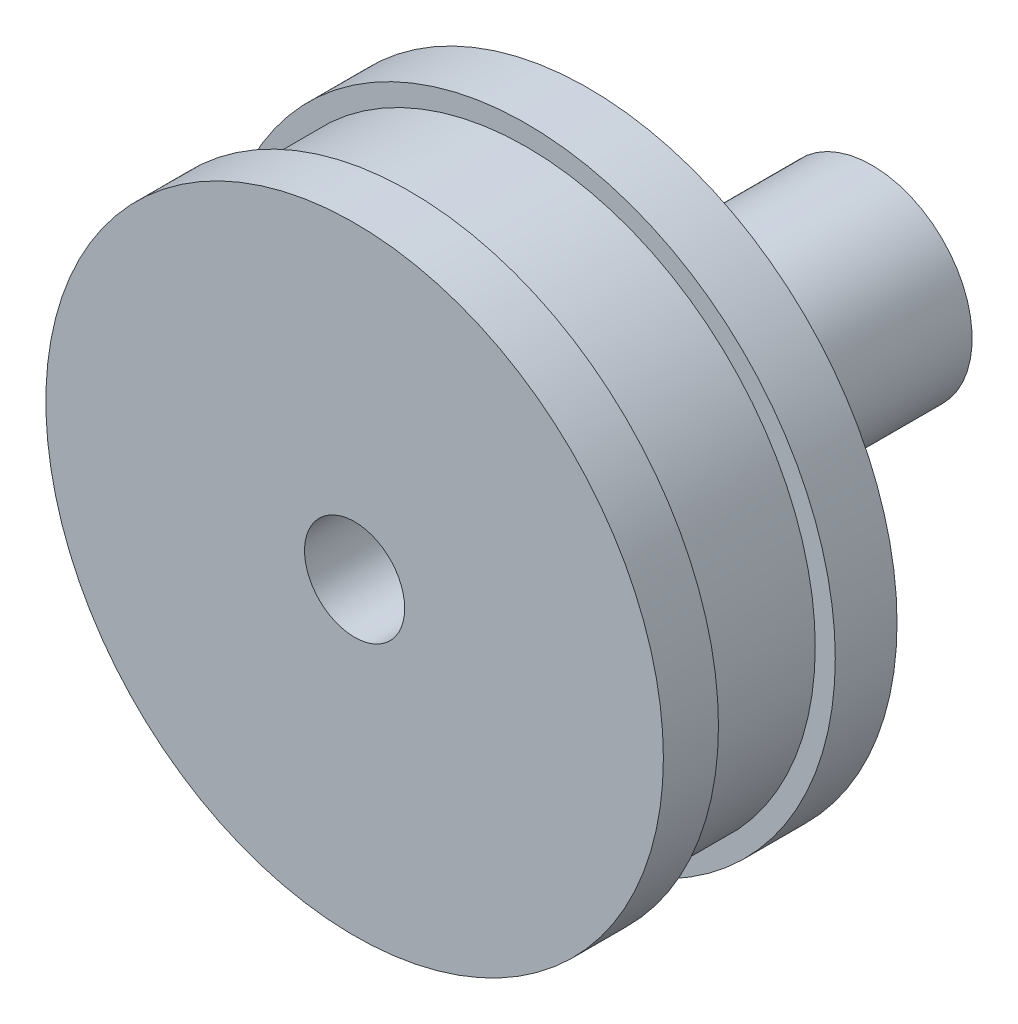
from build123d import *

# Parameters (mm, degrees)
SKETCH_1_R          = 18.5
SKETCH_1_R_2        = 3
EXTRUDE_1_DEPTH     = 14
CUT_EXTRUDE_START   = -2.2
SKETCH_2_R          = 18.5
SKETCH_2_R_2        = 17.3
CUT_EXTRUDE_1_DEPTH = 2.2
SKETCH_2_2_R        = 18.5
SKETCH_2_2_R_2      = 17.3
CUT_EXTRUDE_2_DEPTH = 0.8
CUT_EXTRUDE_START_2 = -4
SKETCH_2_4_R        = 18.5
SKETCH_2_4_R_2      = 17.3
CUT_EXTRUDE_3_DEPTH = 4
SKETCH_2_6_R        = 18.5
SKETCH_2_6_R_2      = 17.3
CUT_EXTRUDE_5_DEPTH = 3
SKETCH_3_R          = 7
EXTRUDE_3_DEPTH     = 5
SKETCH_4_R          = 6
EXTRUDE_4_DEPTH     = 12


with BuildPart() as part:
    # 草图1 → 凸台-拉伸1 (new body)
    with BuildSketch(Plane.XY):
        Circle(SKETCH_1_R)
        Circle(SKETCH_1_R_2, mode=Mode.SUBTRACT)
    extrude(amount=EXTRUDE_1_DEPTH)

    # 草图2 → 切除-拉伸1 (cut)
    with BuildSketch(Plane.XY.offset(7.7).offset(CUT_EXTRUDE_START)):
        Circle(SKETCH_2_R)
        Circle(SKETCH_2_R_2, mode=Mode.SUBTRACT)
    extrude(amount=CUT_EXTRUDE_1_DEPTH, mode=Mode.SUBTRACT)

    # 草图2<2> → 切除-拉伸2 (cut)
    with BuildSketch(Plane.XY.offset(7.7)):
        Circle(SKETCH_2_2_R)
        Circle(SKETCH_2_2_R_2, mode=Mode.SUBTRACT)
    extrude(amount=CUT_EXTRUDE_2_DEPTH, mode=Mode.SUBTRACT)

    # 草图2<4> → 切除-拉伸3 (cut)
    with BuildSketch(Plane.XY.offset(7.7).offset(CUT_EXTRUDE_START_2)):
        Circle(SKETCH_2_4_R)
        Circle(SKETCH_2_4_R_2, mode=Mode.SUBTRACT)
    extrude(amount=CUT_EXTRUDE_3_DEPTH, mode=Mode.SUBTRACT)

    # 草图2<6> → 切除-拉伸5 (cut)
    with BuildSketch(Plane.XY.offset(7.7)):
        Circle(SKETCH_2_6_R)
        Circle(SKETCH_2_6_R_2, mode=Mode.SUBTRACT)
    extrude(amount=CUT_EXTRUDE_5_DEPTH, mode=Mode.SUBTRACT)

    # 草图3 → 凸台-拉伸3 (add)
    with BuildSketch(Plane(origin=(0, 0, 0), x_dir=(-1, 0, 0), z_dir=(0, 0, -1))):
        Circle(SKETCH_3_R)
    extrude(amount=EXTRUDE_3_DEPTH)

    # 草图4 → 凸台-拉伸4 (add)
    with BuildSketch(Plane(origin=(0, 0, -5), x_dir=(-1, 0, 0), z_dir=(0, 0, -1))):
        Circle(SKETCH_4_R)
    extrude(amount=EXTRUDE_4_DEPTH)


solid = part.part
